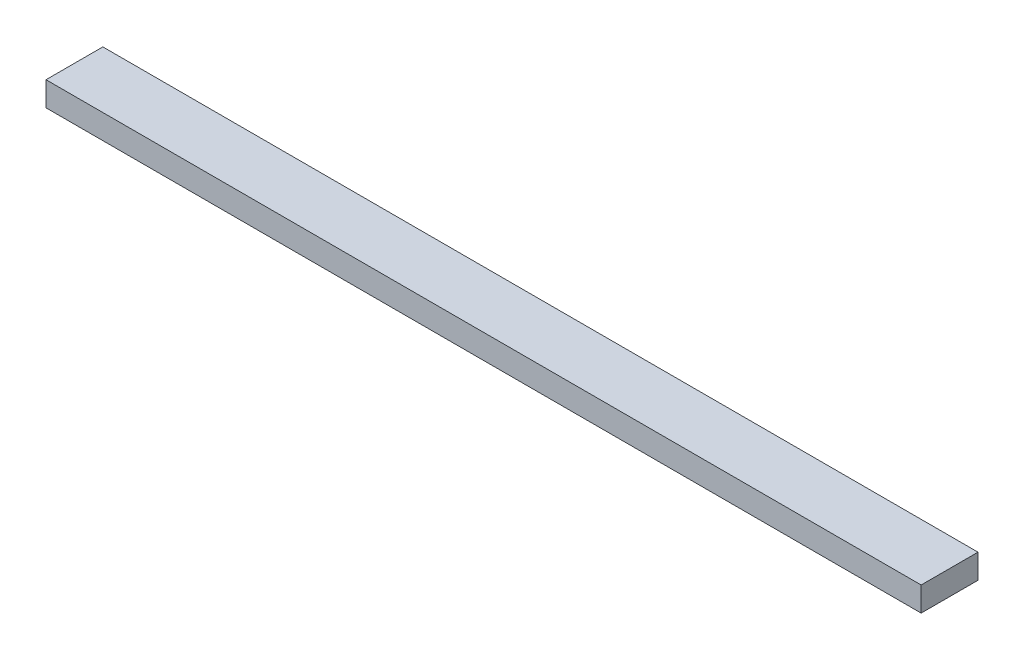
from build123d import *

# Parameters (mm, degrees)
SKETCH1_W           = 1368.4758
SKETCH1_H           = 88.9
BOSS_EXTRUDE1_DEPTH = 38.1


with BuildPart() as part:
    # Sketch1 → Boss-Extrude1 (new body)
    with BuildSketch(Plane(origin=(0, 0, 0), x_dir=(1, 0, 0), z_dir=(0, 1, 0))):
        with Locations((684.2379, 44.45)):
            Rectangle(SKETCH1_W, SKETCH1_H)
    extrude(amount=BOSS_EXTRUDE1_DEPTH)


solid = part.part
